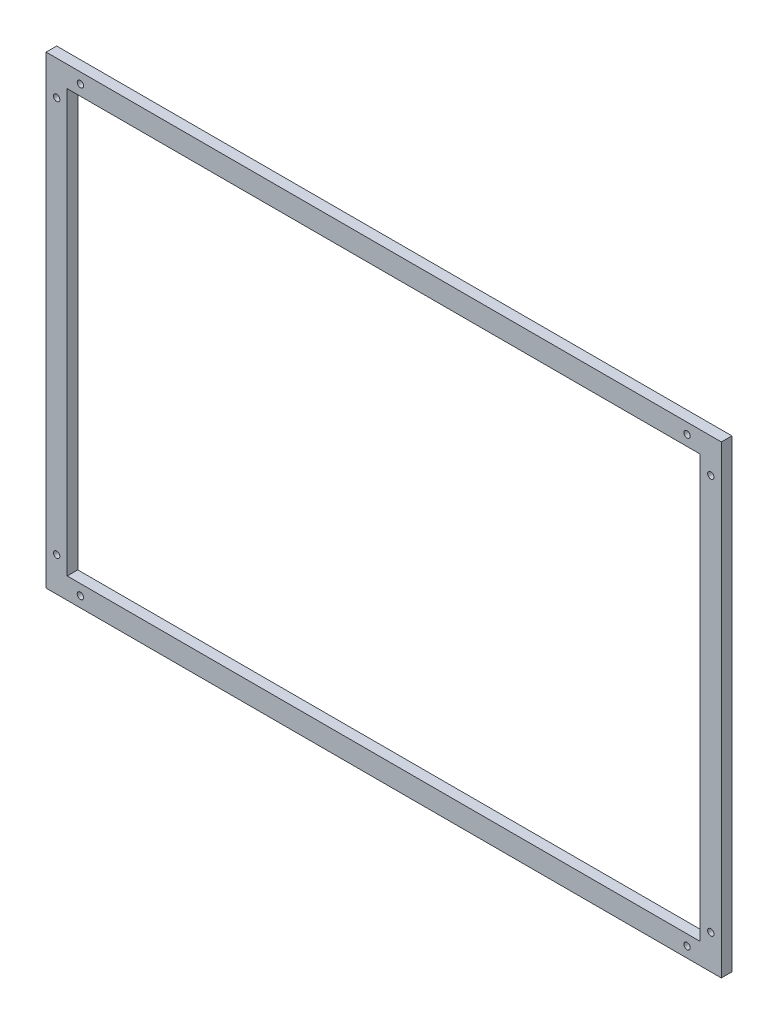
from build123d import *

# Parameters (mm, degrees)
ESQUISSE1_W             = 640
ESQUISSE1_H             = 440
ESQUISSE1_W_2           = 600
ESQUISSE1_H_2           = 400
BOSS_EXTRU_1_DEPTH      = 10
ESQUISSE2_R             = 3
ENL_V_MAT_EXTRU_1_DEPTH = 11


with BuildPart() as part:
    # Esquisse1 → Boss.-Extru.1 (new body)
    with BuildSketch(Plane.XY):
        with Locations((-320, 220)):
            Rectangle(ESQUISSE1_W, ESQUISSE1_H)
        with Locations((-320, 220)):
            Rectangle(ESQUISSE1_W_2, ESQUISSE1_H_2, mode=Mode.SUBTRACT)
    extrude(amount=BOSS_EXTRU_1_DEPTH)

    # Esquisse2 → Enlèv. mat.-Extru.1 (cut, through all)
    with BuildSketch(Plane.XY.offset(10)):
        with Locations((-32.5, 430)):
            Circle(ESQUISSE2_R)
        with Locations((-10, 407.5)):
            Circle(ESQUISSE2_R)
        with Locations((-607.5, 430)):
            Circle(ESQUISSE2_R)
        with Locations((-630, 407.5)):
            Circle(ESQUISSE2_R)
        with Locations((-630, 32.5)):
            Circle(ESQUISSE2_R)
        with Locations((-607.5, 10)):
            Circle(ESQUISSE2_R)
        with Locations((-32.5, 10)):
            Circle(ESQUISSE2_R)
        with Locations((-10, 32.5)):
            Circle(ESQUISSE2_R)
    extrude(amount=-ENL_V_MAT_EXTRU_1_DEPTH, mode=Mode.SUBTRACT)


solid = part.part
